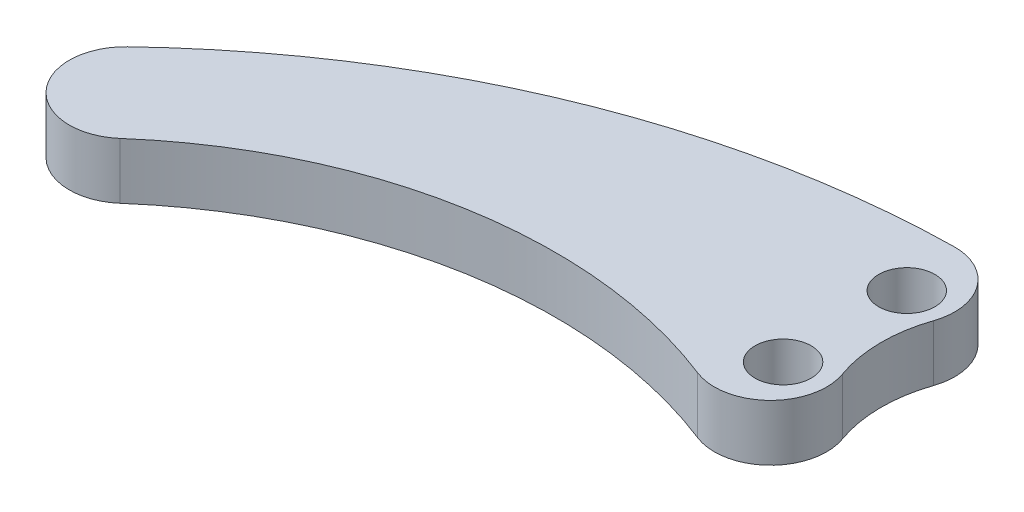
from build123d import *

# Parameters (mm, degrees)
SKETCH1_R           = 5
BOSS_EXTRUDE1_DEPTH = 10
FILLET1_R           = 10


with BuildPart() as part:
    # Sketch1 → Boss-Extrude1 (new body)
    with BuildSketch(Plane(origin=(0, 0, 0), x_dir=(1, 0, 0), z_dir=(0, 1, 0))):
        with BuildLine():
            ThreePointArc((10.228609777, 26.046670488), (6.184117748, 31.09707028), (0, 33))
            ThreePointArc((0, 33), (-57.565554835, 21.913887087), (-106.896551724, -9.75862069))
            ThreePointArc((-106.896551724, -9.75862069), (-107.383655881, -23.74400666), (-93.411472897, -24.522719629))
            ThreePointArc((-93.411472897, -24.522719629), (-50.8758669, -4.476742461), (-4.17684665, -9.983146536))
            ThreePointArc((-4.17684665, -9.983146536), (4.753191306, -9.721956341), (10.443773705, -2.834934477))
            ThreePointArc((10.443773705, -2.834934477), (5.699126861, 11.571322519), (10.228609777, 26.046670488))
        make_face()
        Circle(SKETCH1_R, mode=Mode.SUBTRACT)
        with Locations((0, 22)):
            Circle(SKETCH1_R, mode=Mode.SUBTRACT)
    extrude(amount=BOSS_EXTRUDE1_DEPTH)

    # Fillet1
    fillet1_edges = [part.edges().sort_by_distance(p)[0] for p in [
        (10.443773705, 5, 2.834934477),
        (10.228609777, 5, -26.046670488),
    ]]
    fillet(fillet1_edges, radius=FILLET1_R)


solid = part.part
